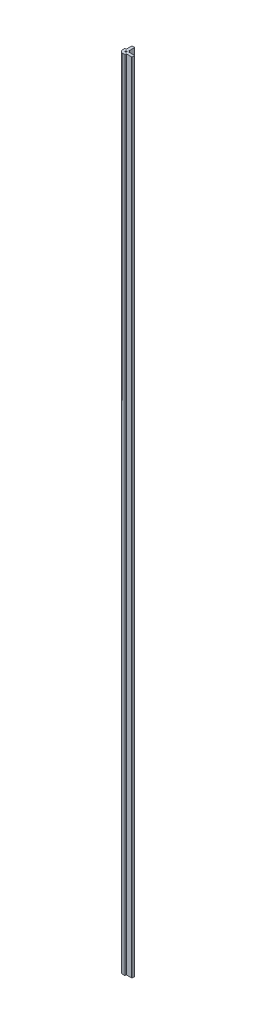
from build123d import *

# Parameters (mm, degrees)
BOSS_EXTRUDE1_DEPTH = 1828.8
THRU_HOLES_D        = 3.4544


with BuildPart() as part:
    # Sketch1 → Boss-Extrude1 (new body)
    with BuildSketch(Plane(origin=(0, 0, 0), x_dir=(1, 0, 0), z_dir=(0, 1, 0))):
        with BuildLine():
            Line((-4.445, 17.018), (-4.445, 4.953))
            ThreePointArc((-4.445, 4.953), (-4.482197439, 4.863197439), (-4.572, 4.826))
            Line((-4.572, 4.826), (-7.366, 4.826))
            ThreePointArc((-7.366, 4.826), (-7.545605122, 4.751605122), (-7.62, 4.572))
            Line((-7.62, 4.572), (-7.62, 0))
            ThreePointArc((-7.62, 0), (-5.388153673, -5.388153673), (0, -7.62))
            Line((0, -7.62), (4.572, -7.62))
            ThreePointArc((4.572, -7.62), (4.751605122, -7.545605122), (4.826, -7.366))
            Line((4.826, -7.366), (4.826, -4.572))
            ThreePointArc((4.826, -4.572), (4.863197439, -4.482197439), (4.953, -4.445))
            Line((4.953, -4.445), (17.018, -4.445))
            ThreePointArc((17.018, -4.445), (17.556815367, -4.221815367), (17.78, -3.683))
            Line((17.78, -3.683), (17.78, 1.143))
            ThreePointArc((17.78, 1.143), (17.556815367, 1.681815367), (17.018, 1.905))
            Line((17.018, 1.905), (4.87752755, 1.905))
            ThreePointArc((4.87752755, 1.905), (4.73895919, 1.946127246), (4.645264333, 2.056190476))
            ThreePointArc((4.645264333, 2.056190476), (3.592102448, 3.592102448), (2.056190476, 4.645264333))
            ThreePointArc((2.056190476, 4.645264333), (1.946127246, 4.73895919), (1.905, 4.87752755))
            Line((1.905, 4.87752755), (1.905, 17.018))
            ThreePointArc((1.905, 17.018), (1.681815367, 17.556815367), (1.143, 17.78))
            Line((1.143, 17.78), (-3.683, 17.78))
            ThreePointArc((-3.683, 17.78), (-4.221815367, 17.556815367), (-4.445, 17.018))
        make_face()
    extrude(amount=BOSS_EXTRUDE1_DEPTH)

    # THRU HOLES (through all)
    with Locations(Plane(origin=(0, 1828.8, 0), x_dir=(1, 0, 0), z_dir=(0, 1, 0))):
        with Locations((0, 0)):
            Hole(THRU_HOLES_D / 2)


solid = part.part
